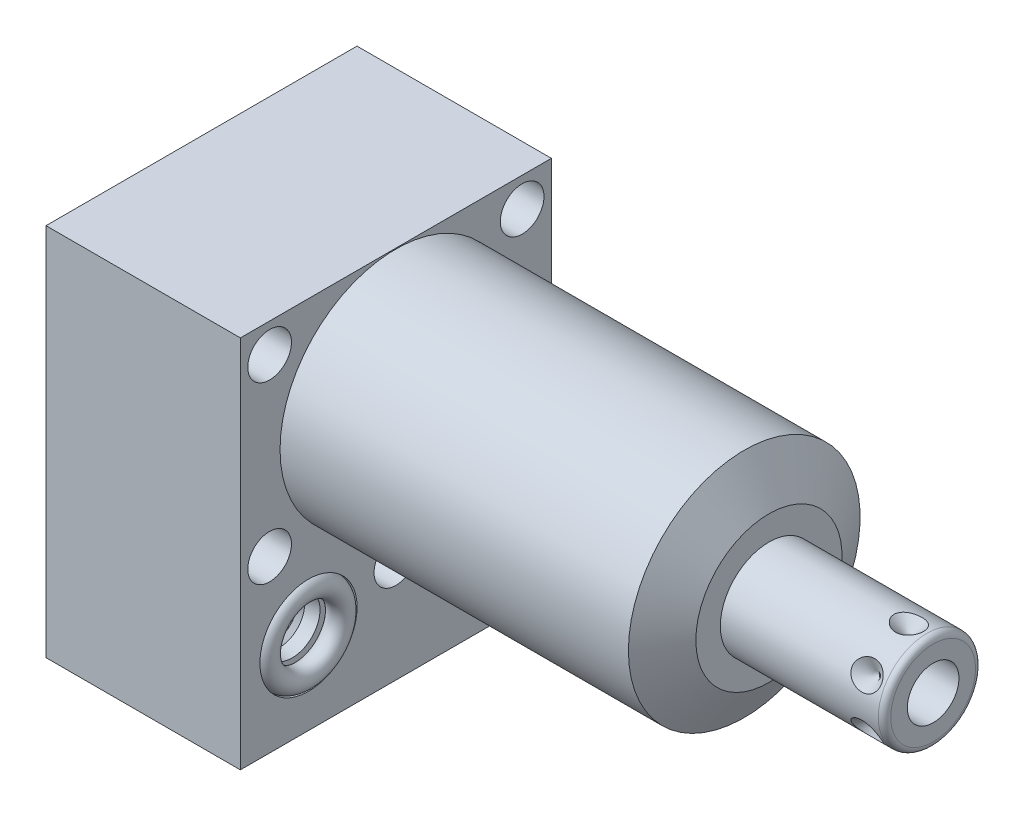
from build123d import *

# Parameters (mm, degrees)
SKETCH1_W           = 50.8
SKETCH1_H           = 61.1124
EXTRUDE1_DEPTH      = 60.9346
EXTRUDE1_DEPTH_BACK = 31.75
CUT_EXTRUDE1_REACH  = 62.935
SKETCH2_W           = 50.8
SKETCH2_H           = 61.1124
SKETCH2_R           = 18.923
SKETCH18_R          = 7.9375
CUT_EXTRUDE2_DEPTH  = 2.667
SKETCH19_R          = 7.9375
CUT_EXTRUDE3_DEPTH  = 2.667
SKETCH20_R          = 9.525
CUT_EXTRUDE4_DEPTH  = 0.254
SKETCH14_R          = 1.7653
SKETCH15_R          = 1.7653
CIRPATTERN1_COUNT   = 6
SKETCH21_W          = 3.5687
SKETCH21_H          = 31.75
HOLE1_AT_2_COUNT    = 2
HOLE1_AT_2_PITCH    = 44.445239059
HOLE1_AT_3_COUNT    = 2
HOLE1_AT_3_PITCH    = 28.5496
HOLE1_AT_4_COUNT    = 2
HOLE1_AT_4_PITCH    = 41.2496
HOLE1_AT_5_COUNT    = 2
HOLE1_AT_5_PITCH    = 50.165816652
LPATTERN1_COUNT     = 2
LPATTERN1_PITCH     = 28.5496


with BuildPart() as part:
    # Sketch1 → Extrude1 (new body, two sides)
    with BuildSketch(Plane(origin=(0, 0, 0), x_dir=(0, 0, -1), z_dir=(1, 0, 0))) as extrude1_sk:
        with Locations((0, -11.5062)):
            Rectangle(SKETCH1_W, SKETCH1_H)
    extrude(amount=EXTRUDE1_DEPTH)
    extrude(extrude1_sk.sketch, amount=-EXTRUDE1_DEPTH_BACK)

    # Sketch2 → Cut-Extrude1 (cut, up to next)
    with BuildSketch(Plane(origin=(0, 0, 0), x_dir=(0, 0, -1), z_dir=(1, 0, 0)), mode=Mode.PRIVATE) as cut_extrude1_sk1:
        with Locations((0, -11.5062)):
            Rectangle(SKETCH2_W, SKETCH2_H)
        Circle(SKETCH2_R, mode=Mode.SUBTRACT)
    cut_extrude1_tool1 = extrude(cut_extrude1_sk1.sketch, amount=CUT_EXTRUDE1_REACH, mode=Mode.PRIVATE) & part.part
    add(cut_extrude1_tool1.solids().sort_by_distance((0, 18.970531, 0))[0], mode=Mode.SUBTRACT)

    # Sketch3 → Cut-Revolve1 (revolve, cut)
    with BuildSketch(Plane.XY, mode=Mode.PRIVATE) as cut_revolve1_sk:
        Polygon((56.90180837, 18.923), (60.9346, 11.938), (60.9346, 18.923), align=None)
    revolve(cut_revolve1_sk.sketch.rotate(Axis((56.700168788, 0, 0), (1, 0, 0)), 90), axis=Axis((56.700168788, 0, 0), (1, 0, 0)), mode=Mode.SUBTRACT)  # turned: the seam where the file's is

    # S2D0002 → Cut-Revolve2 (revolve, cut)
    with BuildSketch(Plane(origin=(-29.083, -28.575, 14.2748), x_dir=(0, 1, 0), z_dir=(0, 0, 1)), mode=Mode.PRIVATE) as cut_revolve2_sk:
        Polygon((0, 0), (4.5466, 0), (4.106586662, -2.0701), (3.4544, -2.722286662), (3.4544, -13.97), (0, -13.97), align=None)
    revolve(cut_revolve2_sk.sketch.rotate(Axis((-14.4145, -28.575, 14.2748), (-1, 0, 0)), 90), axis=Axis((-14.4145, -28.575, 14.2748), (-1, 0, 0)), mode=Mode.SUBTRACT)  # turned: the seam where the file's is

    # Sketch5 → Cut-Revolve3 (revolve, cut)
    with BuildSketch(Plane(origin=(-29.083, -28.575, -14.2748), x_dir=(0, 1, 0), z_dir=(0, 0, 1)), mode=Mode.PRIVATE) as cut_revolve3_sk:
        Polygon((0, 0), (4.5466, 0), (4.106586662, -2.0701), (3.4544, -2.722286662), (3.4544, -13.97), (0, -13.97), align=None)
    revolve(cut_revolve3_sk.sketch.rotate(Axis((-14.4145, -28.575, -14.2748), (-1, 0, 0)), 90), axis=Axis((-14.4145, -28.575, -14.2748), (-1, 0, 0)), mode=Mode.SUBTRACT)  # turned: the seam where the file's is

    # Sketch6 → Cut-Revolve4 (revolve, cut)
    with BuildSketch(Plane(origin=(-2.667, -28.575, 14.2748), x_dir=(0, -1, 0), z_dir=(0, 0, 1)), mode=Mode.PRIVATE) as cut_revolve4_sk:
        Polygon((0, 0), (4.5466, 0), (4.106586662, -2.0701), (3.4544, -2.722286662), (3.4544, -12.192), (0, -12.192), align=None)
    revolve(cut_revolve4_sk.sketch.rotate(Axis((-15.4686, -28.575, 14.2748), (1, 0, 0)), 90), axis=Axis((-15.4686, -28.575, 14.2748), (1, 0, 0)), mode=Mode.SUBTRACT)  # turned: the seam where the file's is

    # Sketch7 → Cut-Revolve5 (revolve, cut)
    with BuildSketch(Plane(origin=(-2.667, -28.575, -14.2748), x_dir=(0, -1, 0), z_dir=(0, 0, 1)), mode=Mode.PRIVATE) as cut_revolve5_sk:
        Polygon((0, 0), (4.5466, 0), (4.106586662, -2.0701), (3.4544, -2.722286662), (3.4544, -12.192), (0, -12.192), align=None)
    revolve(cut_revolve5_sk.sketch.rotate(Axis((-15.4686, -28.575, -14.2748), (1, 0, 0)), 90), axis=Axis((-15.4686, -28.575, -14.2748), (1, 0, 0)), mode=Mode.SUBTRACT)  # turned: the seam where the file's is

    # Sketch18 → Cut-Extrude2 (cut)
    with BuildSketch(Plane.ZY.offset(31.75)):
        with Locations((-14.2748, -28.575)):
            Circle(SKETCH18_R)
        with Locations((14.2748, -28.575)):
            Circle(SKETCH18_R)
    extrude(amount=-CUT_EXTRUDE2_DEPTH, mode=Mode.SUBTRACT)

    # Sketch19 → Cut-Extrude3 (cut)
    with BuildSketch(Plane(origin=(0, 0, 0), x_dir=(0, 0, -1), z_dir=(1, 0, 0))):
        with Locations((-14.2748, -28.575)):
            Circle(SKETCH19_R)
        with Locations((14.2748, -28.575)):
            Circle(SKETCH19_R)
    extrude(amount=-CUT_EXTRUDE3_DEPTH, mode=Mode.SUBTRACT)

    # Sketch8 → Cut-Revolve6 (revolve, cut)
    with BuildSketch(Plane(origin=(-15.875, -43.688, 14.2748), x_dir=(-1, 0, 0), z_dir=(0, 0, 1)), mode=Mode.PRIVATE) as cut_revolve6_sk:
        Polygon((0, -1.8796), (6.1849, -1.8796), (5.642306865, -4.4323), (4.9784, -5.096206865), (4.9784, -20.9296), (0, -20.9296), align=None)
    revolve(cut_revolve6_sk.sketch.rotate(Axis((-15.875, -17.018, 14.2748), (0, -1, 0)), 270), axis=Axis((-15.875, -17.018, 14.2748), (0, -1, 0)), mode=Mode.SUBTRACT)  # turned: the seam where the file's is

    # Sketch9 → Cut-Revolve7 (revolve, cut)
    with BuildSketch(Plane(origin=(-15.875, -43.688, -14.2748), x_dir=(-1, 0, 0), z_dir=(0, 0, 1)), mode=Mode.PRIVATE) as cut_revolve7_sk:
        Polygon((0, -1.8796), (6.1849, -1.8796), (5.642306865, -4.4323), (4.9784, -5.096206865), (4.9784, -20.9296), (0, -20.9296), align=None)
    revolve(cut_revolve7_sk.sketch.rotate(Axis((-15.875, -17.018, -14.2748), (0, -1, 0)), 270), axis=Axis((-15.875, -17.018, -14.2748), (0, -1, 0)), mode=Mode.SUBTRACT)  # turned: the seam where the file's is

    # Sketch20 → Cut-Extrude4 (cut)
    with BuildSketch(Plane.XZ.offset(42.0624)):
        with Locations(Location((-15.875, 14.2748, 0), (0, 0, 270))):  # turned: the seam where the file's is
            Circle(SKETCH20_R)
        with Locations(Location((-15.875, -14.2748, 0), (0, 0, 270))):  # turned: the seam where the file's is
            Circle(SKETCH20_R)
    extrude(amount=-CUT_EXTRUDE4_DEPTH, mode=Mode.SUBTRACT)

    # Sketch10 → Revolve1 (revolve)
    with BuildSketch(Plane.XY, mode=Mode.PRIVATE) as revolve1_sk:
        with BuildLine():
            Line((60.9346, 0), (60.9346, 7.9375))
            Line((60.9346, 7.9375), (86.741, 7.9375))
            ThreePointArc((86.741, 7.9375), (87.45942049, 7.63992049), (87.757, 6.9215))
            Line((87.757, 6.9215), (87.757, 0))
            Line((87.757, 0), (60.9346, 0))
        make_face()
    revolve(revolve1_sk.sketch.rotate(Axis((59.59348, 0, 0), (1, 0, 0)), 90), axis=Axis((59.59348, 0, 0), (1, 0, 0)))  # turned: the seam where the file's is

    # S2D0001 → Cut-Revolve8 (revolve, cut)
    with BuildSketch(Plane(origin=(87.757, -4.2164, 0), x_dir=(0, -1, 0), z_dir=(0, 0, 1)), mode=Mode.PRIVATE) as cut_revolve8_sk:
        Polygon((0, 0), (0, -15.24), (-4.2164, -17.773468714), (-4.2164, 0), align=None)
    revolve(cut_revolve8_sk.sketch.rotate(Axis((62.891960697, 0, 0), (1, 0, 0)), 270), axis=Axis((62.891960697, 0, 0), (1, 0, 0)), mode=Mode.SUBTRACT)  # turned: the seam where the file's is

    # Sketch16 → Cut-Revolve9 (revolve, cut)
    with BuildSketch(Plane(origin=(83.7946, -7.9375, 0), x_dir=(-1, 0, 0), z_dir=(0, 0, 1)), mode=Mode.PRIVATE) as cut_revolve9_sk:
        Polygon((0, 0), (2.413, 0), (0, -2.413), align=None)
    cut_revolve9 = revolve(cut_revolve9_sk.sketch.rotate(Axis((83.7946, -4.132061843, 0), (0, -1, 0)), 90), axis=Axis((83.7946, -4.132061843, 0), (0, -1, 0)), mode=Mode.SUBTRACT)  # turned: the seam where the file's is

    # CirPattern1: Cut-Revolve9 ×6 about axis
    cirpattern1_axis = Axis((60.9356, 0, 0), (-1, 0, 0))
    for i in range(1, CIRPATTERN1_COUNT):
        add(cut_revolve9.rotate(cirpattern1_axis, i * 360 / CIRPATTERN1_COUNT), mode=Mode.SUBTRACT)

    # Sketch21 → Hole1 (revolve, cut)
    with BuildSketch(Plane(origin=(0, 14.2748, 20.6248), x_dir=(0, 0, -1), z_dir=(0, 1, 0))):
        with Locations((1.78435, 15.875)):
            Rectangle(SKETCH21_W, SKETCH21_H)
    hole1 = revolve(axis=Axis((-110, 14.2748, 20.6248), (1, 0, 0)), mode=Mode.SUBTRACT)

    # Hole1 at 2: Hole1 ×2
    with Locations(*[Vector(0, -0.885809163, -0.464049703) * (i * HOLE1_AT_2_PITCH) for i in range(1, HOLE1_AT_2_COUNT)]):
        add(hole1, mode=Mode.SUBTRACT)

    # Hole1 at 3: Hole1 ×2
    with Locations(*[(0, -i * HOLE1_AT_3_PITCH, 0) for i in range(1, HOLE1_AT_3_COUNT)]):
        add(hole1, mode=Mode.SUBTRACT)

    # Hole1 at 4: Hole1 ×2
    with Locations(*[(0, 0, -i * HOLE1_AT_4_PITCH) for i in range(1, HOLE1_AT_4_COUNT)]):
        add(hole1, mode=Mode.SUBTRACT)

    # Hole1 at 5: Hole1 ×2
    with Locations(*[Vector(0, -0.569104659, -0.822265095) * (i * HOLE1_AT_5_PITCH) for i in range(1, HOLE1_AT_5_COUNT)]):
        add(hole1, mode=Mode.SUBTRACT)


with BuildPart() as body_2:
    # Sketch14 → Revolve2 (revolve)
    with BuildSketch(Plane(origin=(0, -28.575, -14.2748), x_dir=(0, 0, -1), z_dir=(0, -1, 0)), mode=Mode.PRIVATE) as revolve2_sk:
        with Locations((6.1722, -0.9017)):
            Circle(SKETCH14_R)
    revolve2 = revolve(revolve2_sk.sketch.rotate(Axis((-2.84353, -28.575, -14.2748), (1, 0, 0)), 180), axis=Axis((-2.84353, -28.575, -14.2748), (1, 0, 0)))  # turned: the seam where the file's is


with BuildPart() as body_3:
    # Sketch15 → Revolve3 (revolve)
    with BuildSketch(Plane(origin=(0, -28.575, -14.2748), x_dir=(0, 0, -1), z_dir=(0, -1, 0)), mode=Mode.PRIVATE) as revolve3_sk:
        with Locations((6.1722, -30.8483)):
            Circle(SKETCH15_R)
    revolve3 = revolve(revolve3_sk.sketch.rotate(Axis((-32.79013, -28.575, -14.2748), (1, 0, 0)), 180), axis=Axis((-32.79013, -28.575, -14.2748), (1, 0, 0)))  # turned: the seam where the file's is


with BuildPart() as lpattern1_1:
    # LPattern1: Revolve2, Revolve3 ×2
    with Locations(*[(0, 0, i * LPATTERN1_PITCH) for i in range(1, LPATTERN1_COUNT)]):
        add(revolve2)
        add(revolve3)


solid = Compound([part.part, body_2.part, body_3.part, lpattern1_1.part])
